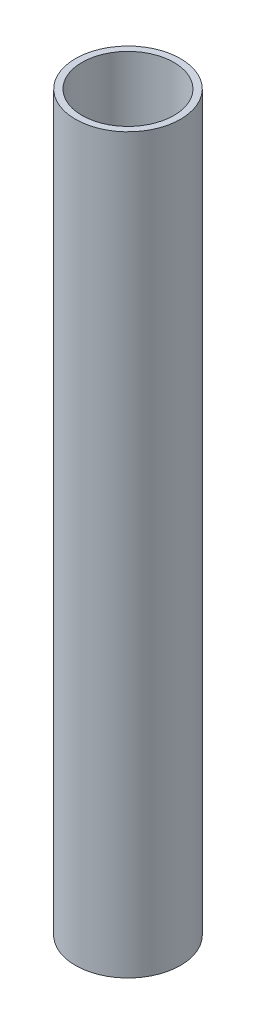
from build123d import *

# Parameters (mm, degrees)
SKETCH1_R           = 12.192
SKETCH1_R_2         = 10.668
BOSS_EXTRUDE1_DEPTH = 170


with BuildPart() as part:
    # Sketch1 → Boss-Extrude1 (new body)
    with BuildSketch(Plane(origin=(0, 0, 0), x_dir=(1, 0, 0), z_dir=(0, 1, 0))):
        Circle(SKETCH1_R)
        Circle(SKETCH1_R_2, mode=Mode.SUBTRACT)
    extrude(amount=BOSS_EXTRUDE1_DEPTH)


solid = part.part
